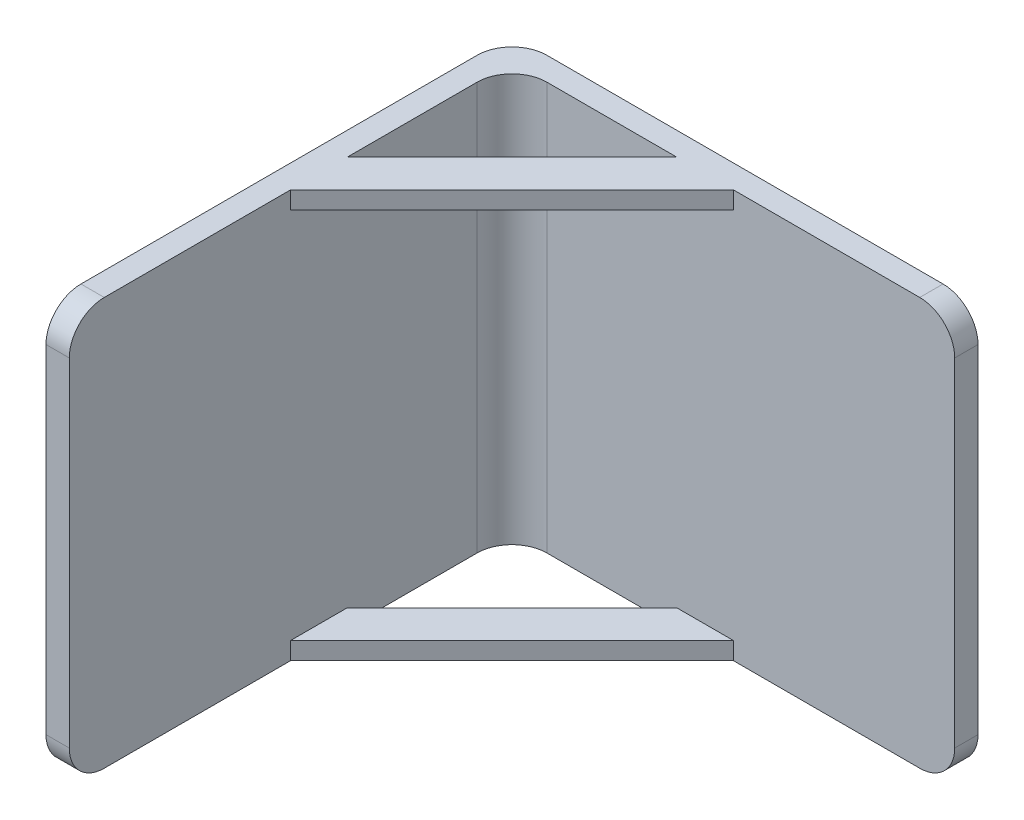
from build123d import *

# Parameters (mm, degrees)
SKETCH1_W           = 40
SKETCH1_H           = 35
BOSS_EXTRUDE1_DEPTH = 2
SKETCH2_W           = 2
SKETCH2_H           = 35
BOSS_EXTRUDE2_DEPTH = 38
FILLET1_R           = 3
BOSS_EXTRUDE3_DEPTH = 1.5
BOSS_EXTRUDE4_START = -33.5
BOSS_EXTRUDE4_DEPTH = 1.5


with BuildPart() as part:
    # Sketch1 → Boss-Extrude1 (new body)
    with BuildSketch(Plane.XY):
        Rectangle(SKETCH1_W, SKETCH1_H)
    extrude(amount=BOSS_EXTRUDE1_DEPTH)

    # Sketch2 → Boss-Extrude2 (add)
    with BuildSketch(Plane.XY.offset(2)):
        with Locations((-19, 0)):
            Rectangle(SKETCH2_W, SKETCH2_H)
    extrude(amount=BOSS_EXTRUDE2_DEPTH)

    # Fillet1
    fillet1_edges = [part.edges().sort_by_distance(p)[0] for p in [
        (-20, 0, 0),
        (-18, 0, 2),
        (20, 17.5, 1),
        (20, -17.5, 1),
        (-19, 17.5, 40),
        (-19, -17.5, 40),
    ]]
    fillet(fillet1_edges, radius=FILLET1_R)

    # Sketch3 → Boss-Extrude3 (add)
    with BuildSketch(Plane.XZ.offset(17.5)):
        Polygon((1, 2), (-18, 21), (-18, 16.142135624), (-3.857864376, 2), align=None)
    extrude(amount=-BOSS_EXTRUDE3_DEPTH)

    # Sketch3_2 → Boss-Extrude4 (add)
    with BuildSketch(Plane.XZ.offset(17.5).offset(BOSS_EXTRUDE4_START)):
        Polygon((1, 2), (-18, 21), (-18, 16.142135624), (-3.857864376, 2), align=None)
    extrude(amount=-BOSS_EXTRUDE4_DEPTH)


solid = part.part
